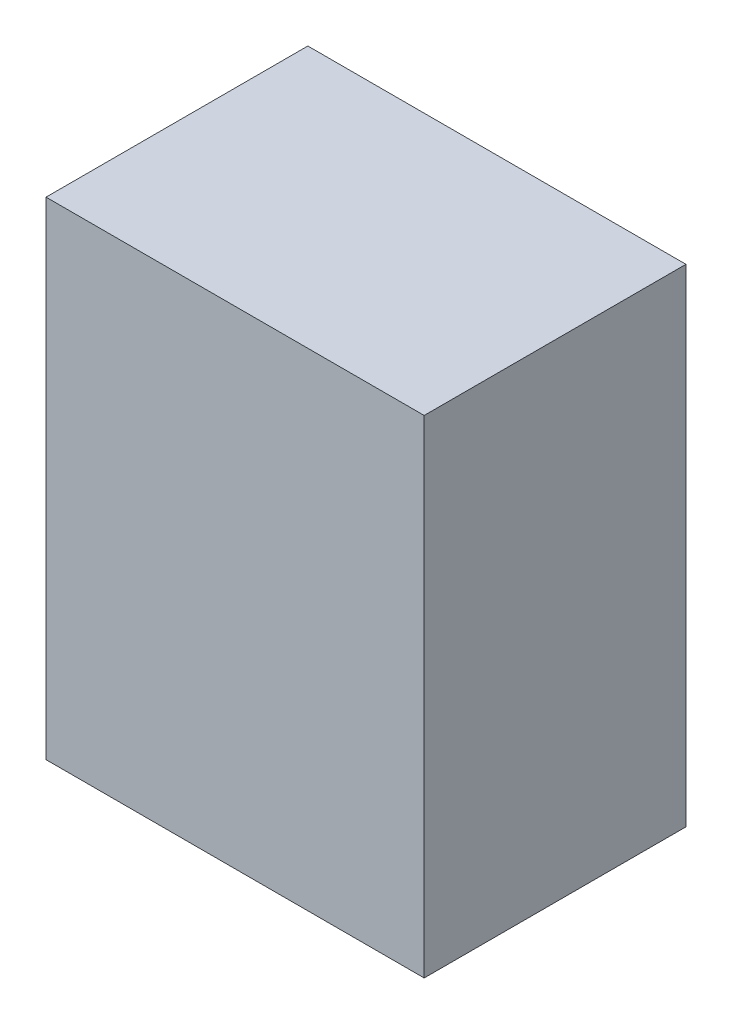
from build123d import *

# Parameters (mm, degrees)
SKETCH1_W           = 660.4
SKETCH1_H           = 457.2
BOSS_EXTRUDE1_DEPTH = 425.45


with BuildPart() as part:
    # Sketch1 → Boss-Extrude1 (new body, symmetric)
    with BuildSketch(Plane(origin=(0, 0, 0), x_dir=(1, 0, 0), z_dir=(0, 1, 0))):
        Rectangle(SKETCH1_W, SKETCH1_H)
    extrude(amount=BOSS_EXTRUDE1_DEPTH, both=True)


solid = part.part
